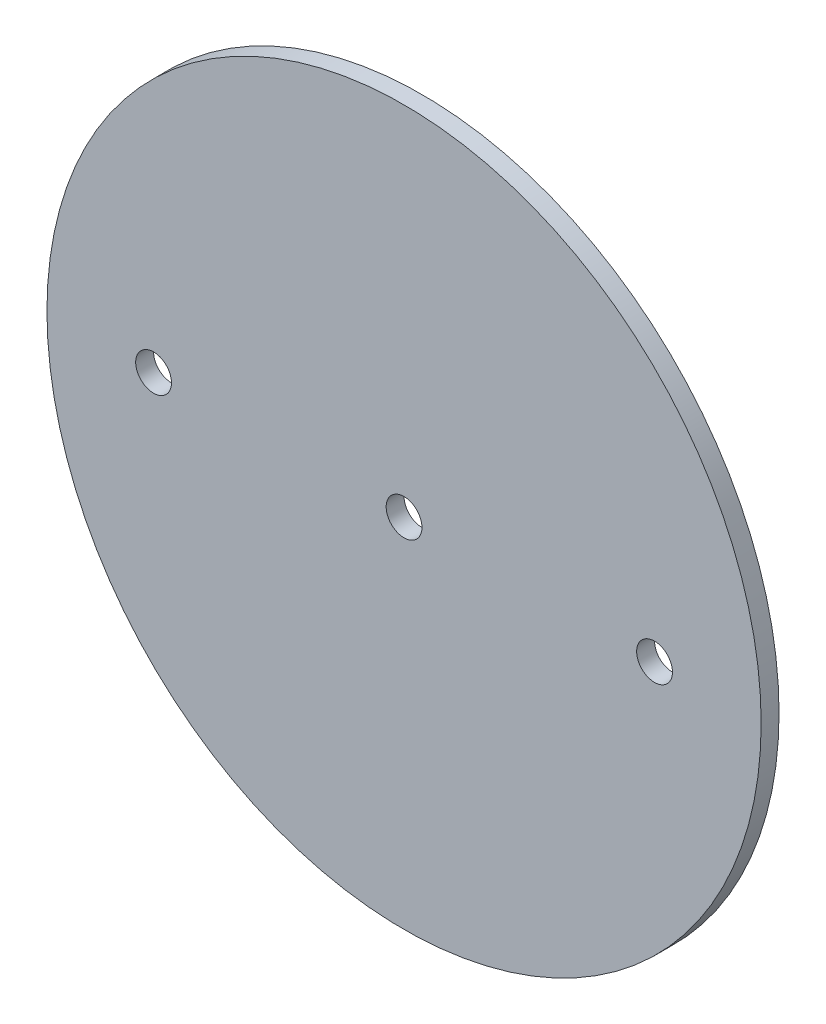
from build123d import *

# Parameters (mm, degrees)
SKETCH1_R                   = 63.373
BOSS_EXTRUDE1_DEPTH         = 1.5875
F_1_4_0_25_DIAMETER_HOLE1_D = 6.35


with BuildPart() as part:
    # Sketch1 → Boss-Extrude1 (new body, symmetric)
    with BuildSketch(Plane.XY):
        Circle(SKETCH1_R)
    extrude(amount=BOSS_EXTRUDE1_DEPTH, both=True)

    # 1/4 (0.25) Diameter Hole1 (through all)
    with Locations(Plane.XY.offset(1.5875)):
        with Locations((-44.45, 0), (0, 0), (44.45, 0)):
            Hole(F_1_4_0_25_DIAMETER_HOLE1_D / 2)


solid = part.part
